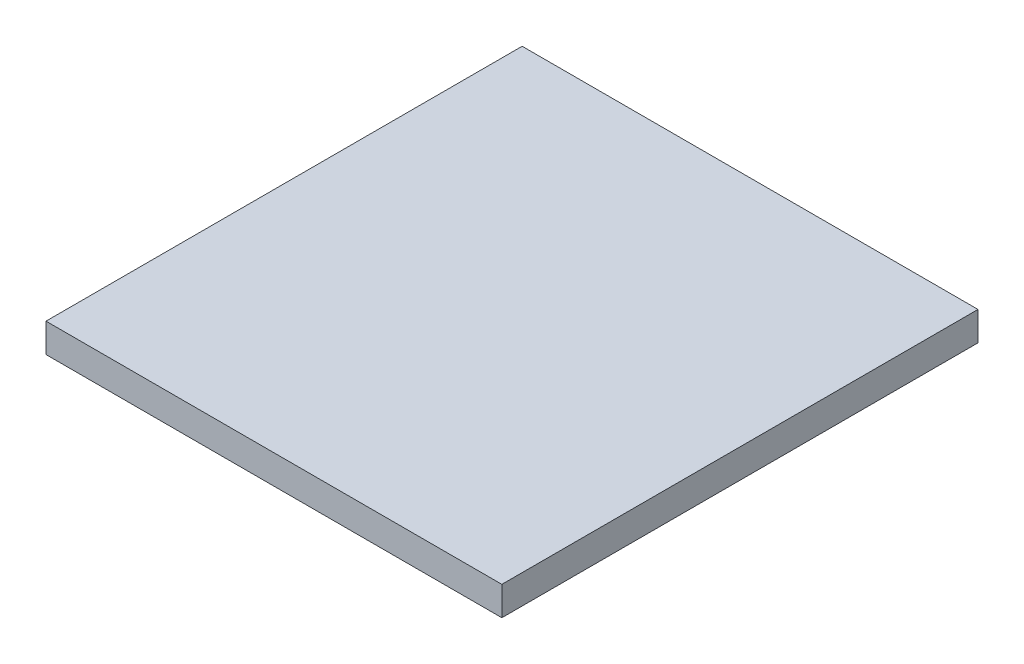
from build123d import *

# Parameters (mm, degrees)
SKETCH1_W           = 600
SKETCH1_H           = 626.71
BOSS_EXTRUDE1_DEPTH = 38.1


with BuildPart() as part:
    # Sketch1 → Boss-Extrude1 (new body)
    with BuildSketch(Plane(origin=(0, 0, 0), x_dir=(1, 0, 0), z_dir=(0, 1, 0))):
        Rectangle(SKETCH1_W, SKETCH1_H)
    extrude(amount=BOSS_EXTRUDE1_DEPTH)


solid = part.part
